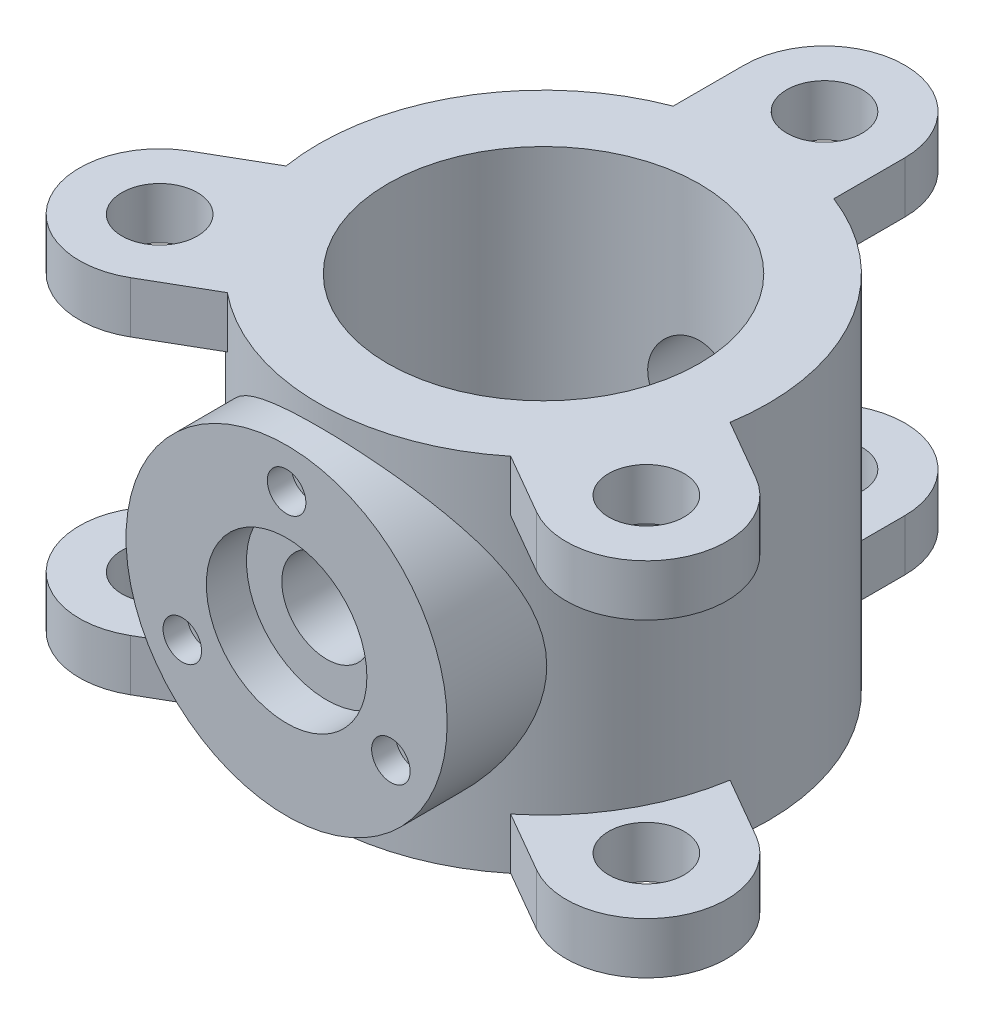
from build123d import *

# Parameters (mm, degrees)
SKETCH1_R                   = 140
SKETCH1_R_2                 = 97
BOSS_EXTRUDE1_DEPTH         = 225
SKETCH2_R                   = 23.5
BOSS_EXTRUDE2_DEPTH         = 32
CIRPATTERN1_COUNT           = 3
LPATTERN2_COUNT             = 2
LPATTERN2_PITCH             = 193
CIRPATTERN2_COPY_1_SKETCH_R = 23.5
CIRPATTERN2_COPY_1_DEPTH    = 32
CIRPATTERN2_COPY_2_SKETCH_R = 23.5
CIRPATTERN2_COPY_2_DEPTH    = 32
CIRPATTERN2_COPY_3_SKETCH_R = 23.5
CIRPATTERN2_COPY_3_DEPTH    = 32
CIRPATTERN2_COPY_4_SKETCH_R = 23.5
CIRPATTERN2_COPY_4_DEPTH    = 32
BOSS_EXTRUDE3_REACH         = 387
SKETCH3_R                   = 100
SKETCH4_R                   = 28
CUT_EXTRUDE1_DEPTH          = 386
SKETCH5_R                   = 50
CUT_EXTRUDE2_DEPTH          = 25
SKETCH6_R                   = 12
CUT_EXTRUDE3_DEPTH          = 15


with BuildPart() as part:
    # Sketch1 → Boss-Extrude1 (new body)
    with BuildSketch(Plane(origin=(0, 0, 0), x_dir=(1, 0, 0), z_dir=(0, 1, 0))):
        Circle(SKETCH1_R)
        Circle(SKETCH1_R_2, mode=Mode.SUBTRACT)
    extrude(amount=BOSS_EXTRUDE1_DEPTH)

    # Sketch2 → Boss-Extrude2 (add)
    with BuildSketch(Plane(origin=(0, 225, 0), x_dir=(1, 0, 0), z_dir=(0, 1, 0))):
        with BuildLine():
            Line((-50, 130.766968306), (-50, 175))
            ThreePointArc((-50, 175), (0, 225), (50, 175))
            Line((50, 175), (50, 130.766968306))
            ThreePointArc((50, 130.766968306), (0, 140), (-50, 130.766968306))
        make_face()
        with Locations((0, 175)):
            Circle(SKETCH2_R, mode=Mode.SUBTRACT)
    boss_extrude2 = extrude(amount=-BOSS_EXTRUDE2_DEPTH)

    # CirPattern1: Boss-Extrude2 ×3 about axis
    cirpattern1_axis = Axis((0, 0, 0), (0, 1, 0))
    for i in range(1, CIRPATTERN1_COUNT):
        add(boss_extrude2.rotate(cirpattern1_axis, i * 360 / CIRPATTERN1_COUNT))

    # LPattern2: Boss-Extrude2 ×2
    with Locations(*[(0, -i * LPATTERN2_PITCH, 0) for i in range(1, LPATTERN2_COUNT)]):
        add(boss_extrude2)

    # CirPattern2 copy 1 sketch → CirPattern2 copy 1 (add)
    with BuildSketch(Plane(origin=(0, 32, 0), x_dir=(-0.5, 0, -0.866025404), z_dir=(0, 1, 0))):
        with BuildLine():
            Line((-50, 130.766968306), (-50, 175))
            ThreePointArc((-50, 175), (0, 225), (50, 175))
            Line((50, 175), (50, 130.766968306))
            ThreePointArc((50, 130.766968306), (0, 140), (-50, 130.766968306))
        make_face()
        with Locations((0, 175)):
            Circle(CIRPATTERN2_COPY_1_SKETCH_R, mode=Mode.SUBTRACT)
    extrude(amount=-CIRPATTERN2_COPY_1_DEPTH)

    # CirPattern2 copy 2 sketch → CirPattern2 copy 2 (add)
    with BuildSketch(Plane(origin=(0, 32, 0), x_dir=(-0.5, 0, 0.866025404), z_dir=(0, 1, 0))):
        with BuildLine():
            Line((-50, 130.766968306), (-50, 175))
            ThreePointArc((-50, 175), (0, 225), (50, 175))
            Line((50, 175), (50, 130.766968306))
            ThreePointArc((50, 130.766968306), (0, 140), (-50, 130.766968306))
        make_face()
        with Locations((0, 175)):
            Circle(CIRPATTERN2_COPY_2_SKETCH_R, mode=Mode.SUBTRACT)
    extrude(amount=-CIRPATTERN2_COPY_2_DEPTH)

    # CirPattern2 copy 3 sketch → CirPattern2 copy 3 (add)
    with BuildSketch(Plane(origin=(0, 225, 0), x_dir=(-0.5, 0, -0.866025404), z_dir=(0, 1, 0))):
        with BuildLine():
            Line((-50, 130.766968306), (-50, 175))
            ThreePointArc((-50, 175), (0, 225), (50, 175))
            Line((50, 175), (50, 130.766968306))
            ThreePointArc((50, 130.766968306), (0, 140), (-50, 130.766968306))
        make_face()
        with Locations((0, 175)):
            Circle(CIRPATTERN2_COPY_3_SKETCH_R, mode=Mode.SUBTRACT)
    extrude(amount=-CIRPATTERN2_COPY_3_DEPTH)

    # CirPattern2 copy 4 sketch → CirPattern2 copy 4 (add)
    with BuildSketch(Plane(origin=(0, 225, 0), x_dir=(-0.5, 0, 0.866025404), z_dir=(0, 1, 0))):
        with BuildLine():
            Line((-50, 130.766968306), (-50, 175))
            ThreePointArc((-50, 175), (0, 225), (50, 175))
            Line((50, 175), (50, 130.766968306))
            ThreePointArc((50, 130.766968306), (0, 140), (-50, 130.766968306))
        make_face()
        with Locations((0, 175)):
            Circle(CIRPATTERN2_COPY_4_SKETCH_R, mode=Mode.SUBTRACT)
    extrude(amount=-CIRPATTERN2_COPY_4_DEPTH)

    # Sketch3 → Boss-Extrude3 (add, up to next)
    with BuildSketch(Plane.XY.offset(160), mode=Mode.PRIVATE) as boss_extrude3_sk1:
        with Locations((0, 112.5)):
            Circle(SKETCH3_R)
    boss_extrude3_tool1 = extrude(boss_extrude3_sk1.sketch, amount=-BOSS_EXTRUDE3_REACH, mode=Mode.PRIVATE) - part.part
    add(boss_extrude3_tool1.solids().sort_by_distance((0, 112.5, 160))[0])

    # Sketch4 → Cut-Extrude1 (cut, through all)
    with BuildSketch(Plane.XY.offset(160)):
        with Locations((0, 112.5)):
            Circle(SKETCH4_R)
    extrude(amount=-CUT_EXTRUDE1_DEPTH, mode=Mode.SUBTRACT)

    # Sketch5 → Cut-Extrude2 (cut)
    with BuildSketch(Plane.XY.offset(160)):
        with Locations((0, 112.5)):
            Circle(SKETCH5_R)
    extrude(amount=-CUT_EXTRUDE2_DEPTH, mode=Mode.SUBTRACT)

    # Sketch6 → Cut-Extrude3 (cut)
    with BuildSketch(Plane.XY.offset(160)):
        with Locations((0, 187.5)):
            Circle(SKETCH6_R)
        with Locations((64.951905284, 75)):
            Circle(SKETCH6_R)
        with Locations((-64.951905284, 75)):
            Circle(SKETCH6_R)
    extrude(amount=-CUT_EXTRUDE3_DEPTH, mode=Mode.SUBTRACT)


solid = part.part
